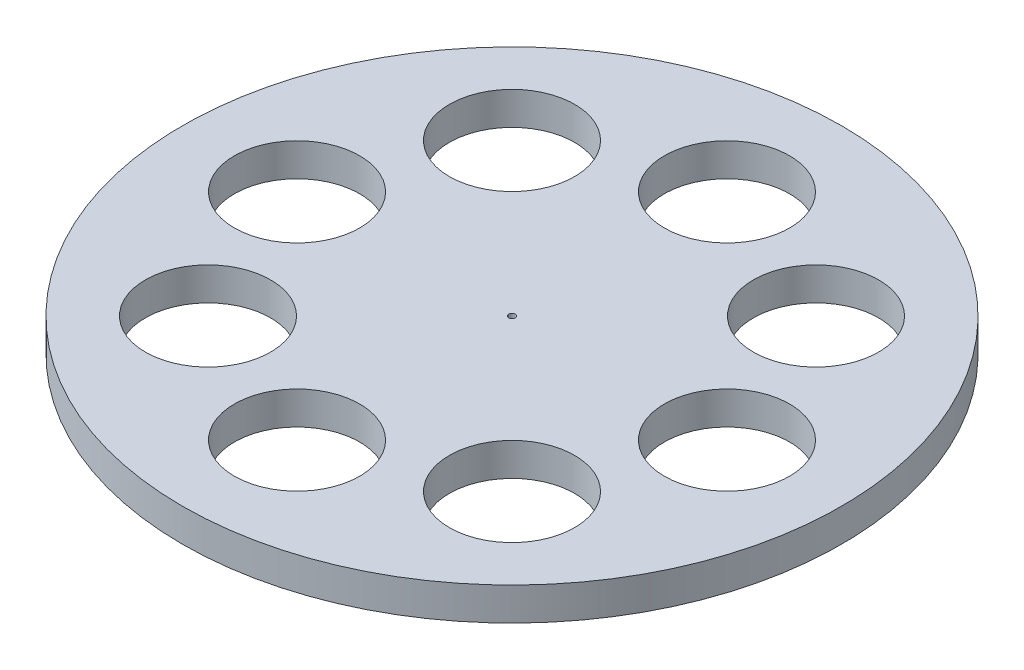
from build123d import *

# Parameters (mm, degrees)
SKETCH1_R           = 50
BOSS_EXTRUDE1_DEPTH = 5
SKETCH2_R           = 9.5
SKETCH2_R_2         = 0.5
CUT_EXTRUDE1_DEPTH  = 5


with BuildPart() as part:
    # Sketch1 → Boss-Extrude1 (new body)
    with BuildSketch(Plane(origin=(0, 0, 0), x_dir=(1, 0, 0), z_dir=(0, 1, 0))):
        Circle(SKETCH1_R)
    extrude(amount=BOSS_EXTRUDE1_DEPTH)

    # Sketch2 → Cut-Extrude1 (cut)
    with BuildSketch(Plane(origin=(0, 5, 0), x_dir=(1, 0, 0), z_dir=(0, 1, 0))):
        with Locations((0, 32.614161607)):
            Circle(SKETCH2_R)
        Circle(SKETCH2_R_2)
        with Locations((23.061694835, 23.061694835)):
            Circle(SKETCH2_R)
        with Locations((32.614161607, 0)):
            Circle(SKETCH2_R)
        with Locations((23.061694835, -23.061694835)):
            Circle(SKETCH2_R)
        with Locations((0, -32.614161607)):
            Circle(SKETCH2_R)
        with Locations((-23.061694835, -23.061694835)):
            Circle(SKETCH2_R)
        with Locations((-32.614161607, 0)):
            Circle(SKETCH2_R)
        with Locations((-23.061694835, 23.061694835)):
            Circle(SKETCH2_R)
    extrude(amount=-CUT_EXTRUDE1_DEPTH, mode=Mode.SUBTRACT)


solid = part.part
